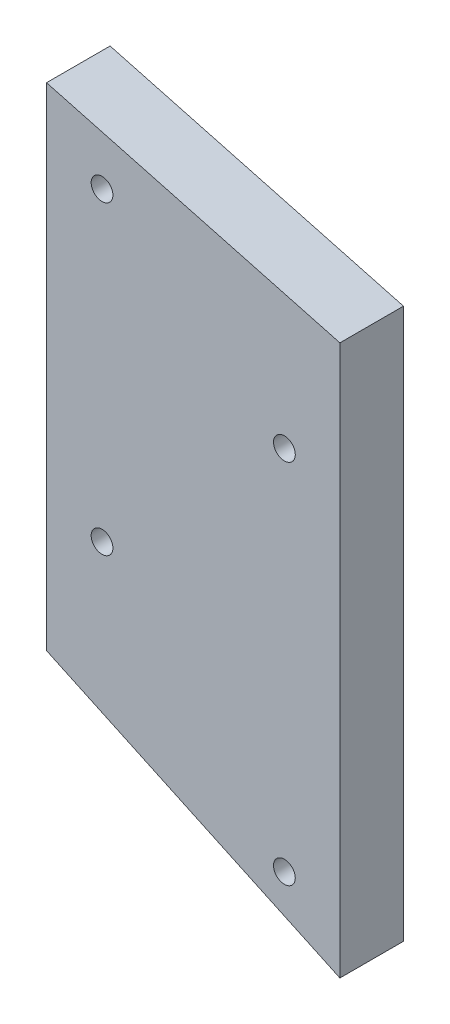
from build123d import *

# Parameters (mm, degrees)
BOSS_EXTRUDE1_DEPTH       = 6.604
F_4_40_TAPPED_HOLE1_D     = 2.2606
F_4_40_TAPPED_HOLE1_DEPTH = 7.5946
F_4_40_TAPPED_HOLE1_TIP   = 0.679152758


with BuildPart() as part:
    # Sketch1 → Boss-Extrude1 (new body)
    with BuildSketch(Plane.XY):
        Polygon((15.24, -32.658545693), (-15.24, -18.445488272), (-15.24, 32.658545693), (15.24, 24.491454307), align=None)
    extrude(amount=BOSS_EXTRUDE1_DEPTH)

    # #4-40 Tapped Hole1
    with Locations(Plane.XY.offset(6.604)):
        with Locations((-9.4742, 25.9842), (9.4742, 12.1158), (-9.4742, -5.7658), (9.4742, -25.9842)):
            Hole(F_4_40_TAPPED_HOLE1_D / 2, depth=F_4_40_TAPPED_HOLE1_DEPTH)
            with Locations((0, 0, -(F_4_40_TAPPED_HOLE1_DEPTH + F_4_40_TAPPED_HOLE1_TIP / 2))):  # 118° drill point
                Cone(0, F_4_40_TAPPED_HOLE1_D / 2, F_4_40_TAPPED_HOLE1_TIP, mode=Mode.SUBTRACT)


solid = part.part
